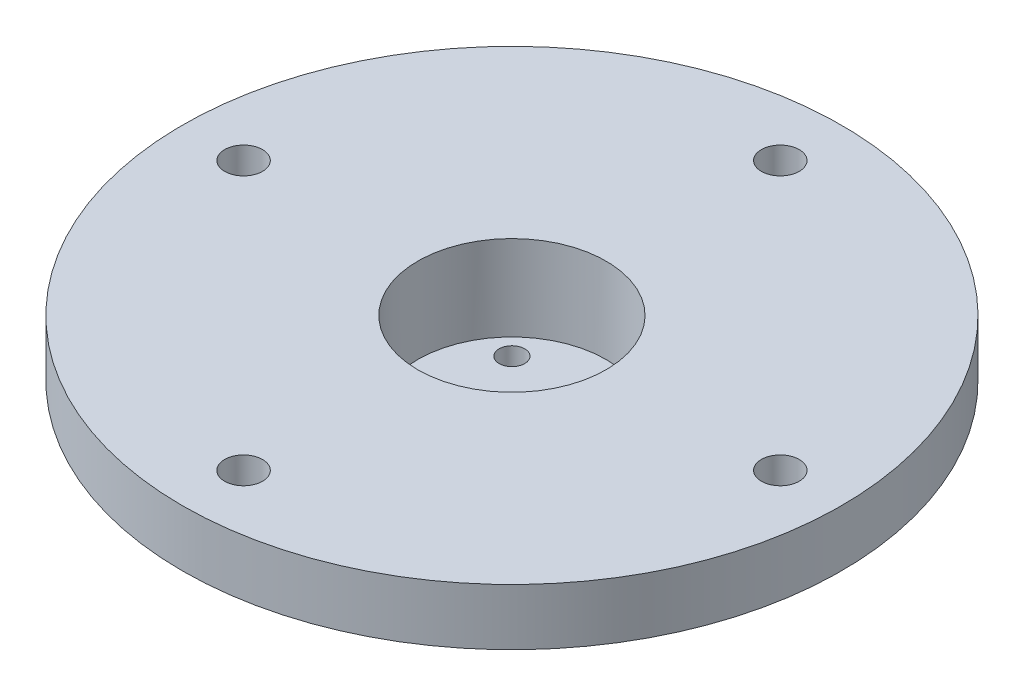
from build123d import *

# Parameters (mm, degrees)
SKETCH1_R           = 15.875
BOSS_EXTRUDE1_DEPTH = 25.4
SKETCH4_R           = 44.45
BOSS_EXTRUDE2_DEPTH = 7.62
SKETCH6_R           = 2.5527
CUT_EXTRUDE4_DEPTH  = 26.4
CIRPATTERN2_COUNT   = 4
CUT_EXTRUDE5_START  = -11.49604
SKETCH2_R           = 12.7
CUT_EXTRUDE5_DEPTH  = 11.49604
CHAMFER1_SIZE       = 2.38
SKETCH3_R           = 1.7272
CUT_EXTRUDE6_DEPTH  = 26.4


with BuildPart() as part:
    # Sketch1 → Boss-Extrude1 (new body)
    with BuildSketch(Plane(origin=(0, 0, 0), x_dir=(1, 0, 0), z_dir=(0, 1, 0))):
        Circle(SKETCH1_R)
    extrude(amount=BOSS_EXTRUDE1_DEPTH)

    # Sketch4 → Boss-Extrude2 (add)
    with BuildSketch(Plane(origin=(0, 25.4, 0), x_dir=(1, 0, 0), z_dir=(0, 1, 0))):
        Circle(SKETCH4_R)
    extrude(amount=-BOSS_EXTRUDE2_DEPTH)

    # Sketch6 → Cut-Extrude4 (cut, through all)
    with BuildSketch(Plane(origin=(0, 25.4, 0), x_dir=(1, 0, 0), z_dir=(0, 1, 0))):
        with Locations((0, 36.195)):
            Circle(SKETCH6_R)
    cut_extrude4 = extrude(amount=-CUT_EXTRUDE4_DEPTH, mode=Mode.SUBTRACT)

    # CirPattern2: Cut-Extrude4 ×4 about axis
    cirpattern2_axis = Axis((0, 0, 0), (0, 1, 0))
    for i in range(1, CIRPATTERN2_COUNT):
        add(cut_extrude4.rotate(cirpattern2_axis, i * 360 / CIRPATTERN2_COUNT), mode=Mode.SUBTRACT)

    # Sketch2 → Cut-Extrude5 (cut)
    with BuildSketch(Plane(origin=(0, 25.4, 0), x_dir=(1, 0, 0), z_dir=(0, 1, 0)).offset(CUT_EXTRUDE5_START)):
        Circle(SKETCH2_R)
    extrude(amount=CUT_EXTRUDE5_DEPTH, mode=Mode.SUBTRACT)

    # Chamfer1
    chamfer1_edges = [part.edges().sort_by_distance(p)[0] for p in [
        (-15.875, 17.78, 0),
    ]]
    chamfer(chamfer1_edges, length=CHAMFER1_SIZE)

    # Sketch3 → Cut-Extrude6 (cut, through all)
    with BuildSketch(Plane.XZ):
        with Locations((6.735192091, -6.735192091)):
            Circle(SKETCH3_R)
        with Locations((-6.735192091, -6.735192091)):
            Circle(SKETCH3_R)
        with Locations((-6.735192091, 6.735192091)):
            Circle(SKETCH3_R)
        with Locations((6.735192091, 6.735192091)):
            Circle(SKETCH3_R)
    extrude(amount=-CUT_EXTRUDE6_DEPTH, mode=Mode.SUBTRACT)


solid = part.part
